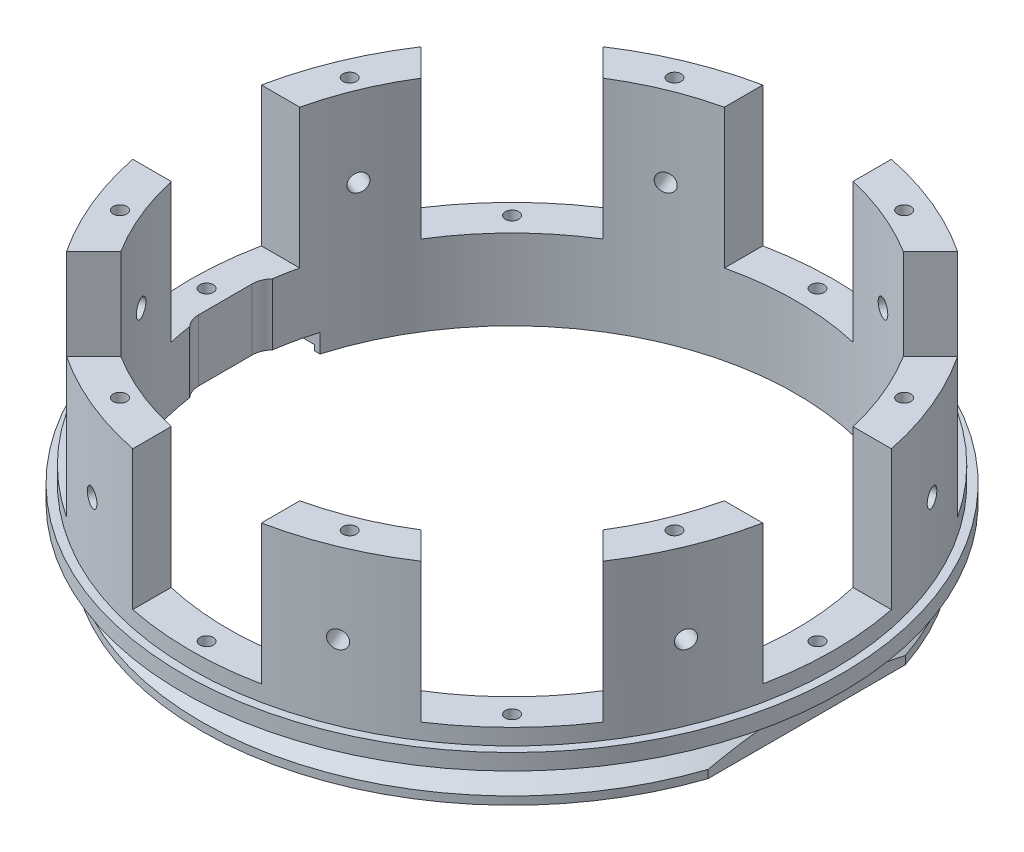
from build123d import *

# Parameters (mm, degrees)
SKIZZE2_W                            = 24
SKIZZE2_H                            = 26
SCHNITT_LINEAR_AUSTRAGEN1_DEPTH      = 62.5
KREISMUSTER1_COUNT                   = 8
SKIZZE3_R                            = 1.65
SCHNITT_LINEAR_AUSTRAGEN2_DEPTH      = 29.067398613
KREISMUSTER2_COUNT                   = 8
SKIZZE4_R                            = 1.25
SCHNITT_LINEAR_AUSTRAGEN3_DEPTH      = 6
SCHNITT_LINEAR_AUSTRAGEN3_DEPTH_BACK = 27.0000001
SCHNITT_LINEAR_AUSTRAGEN4_REACH      = 42
SKIZZE5_W                            = 3
SKIZZE5_H                            = 36.82390528
SKIZZE6_W                            = 7.166939891
SKIZZE6_H                            = 30
SCHNITT_LINEAR_AUSTRAGEN5_DEPTH      = 2.0000001
SCHNITT_LINEAR_AUSTRAGEN5_DEPTH_BACK = 2.5
SKIZZE12_R                           = 1.25
SCHNITT_LINEAR_AUSTRAGEN6_DEPTH      = 10
SCHNITT_LINEAR_AUSTRAGEN7_REACH      = 39.5


with BuildPart() as part:
    # Skizze1 → Rotation1 (revolve)
    with BuildSketch(Plane.XY):
        Polygon((-53, -1), (-53, 40), (-60, 40), (-60, 11), (-61.5, 11), (-61.5, 8), (-55, 8), (-55, 3.600622615), (-58, 1.5), (-58, 0), (-54, 0), (-54, -1), align=None)
    revolve(axis=Axis((0, 0, 0), (0, 1, 0)))

    # Skizze2 → Schnitt-Linear austragen1 (cut, through all)
    with BuildSketch(Plane(origin=(0, 0, 0), x_dir=(0, 0, -1), z_dir=(1, 0, 0))):
        with Locations((0, 27)):
            Rectangle(SKIZZE2_W, SKIZZE2_H)
    schnitt_linear_austragen1 = extrude(amount=-SCHNITT_LINEAR_AUSTRAGEN1_DEPTH, mode=Mode.SUBTRACT)

    # Kreismuster1: Schnitt-Linear austragen1 ×8 about axis
    kreismuster1_axis = Axis((0, 0, 0), (0, 1, 0))
    for i in range(1, KREISMUSTER1_COUNT):
        add(schnitt_linear_austragen1.rotate(kreismuster1_axis, i * 360 / KREISMUSTER1_COUNT), mode=Mode.SUBTRACT)

    # Skizze3 → Schnitt-Linear austragen2 (cut, through all)
    with BuildSketch(Plane(origin=(20.009071561, 0, 48.306171934), x_dir=(-0.923879533, 0, 0.382683432), z_dir=(-0.382683432, 0, -0.923879533))):
        with Locations((0, 25)):
            Circle(SKIZZE3_R)
    schnitt_linear_austragen2 = extrude(amount=-SCHNITT_LINEAR_AUSTRAGEN2_DEPTH, mode=Mode.SUBTRACT)

    # Kreismuster2: Schnitt-Linear austragen2 ×8 about axis
    kreismuster2_axis = Axis((0, 0, 0), (0, -1, 0))
    for i in range(1, KREISMUSTER2_COUNT):
        add(schnitt_linear_austragen2.rotate(kreismuster2_axis, i * 360 / KREISMUSTER2_COUNT), mode=Mode.SUBTRACT)

    # Skizze4 → Schnitt-Linear austragen3 (cut, two sides)
    with BuildSketch(Plane(origin=(0, 14, 0), x_dir=(-1, 0, 0), z_dir=(0, -1, 0))) as schnitt_linear_austragen3_sk:
        with Locations((0, 57)):
            Circle(SKIZZE4_R)
        with Locations((40.305086528, 40.305086528)):
            Circle(SKIZZE4_R)
        with Locations((57, 0)):
            Circle(SKIZZE4_R)
        with Locations((40.305086528, -40.305086528)):
            Circle(SKIZZE4_R)
        with Locations((0, -57)):
            Circle(SKIZZE4_R)
        with Locations((-40.305086528, -40.305086528)):
            Circle(SKIZZE4_R)
        with Locations((-57, 0)):
            Circle(SKIZZE4_R)
        with Locations((-40.305086528, 40.305086528)):
            Circle(SKIZZE4_R)
    extrude(amount=SCHNITT_LINEAR_AUSTRAGEN3_DEPTH, mode=Mode.SUBTRACT)
    extrude(schnitt_linear_austragen3_sk.sketch, amount=-SCHNITT_LINEAR_AUSTRAGEN3_DEPTH_BACK, mode=Mode.SUBTRACT)

    # Skizze5 → Schnitt-Linear austragen4 (cut, up to next)
    with BuildSketch(Plane.XZ, mode=Mode.PRIVATE) as schnitt_linear_austragen4_sk1:
        with Locations((56.5, 0)):
            Rectangle(SKIZZE5_W, SKIZZE5_H)
    schnitt_linear_austragen4_tool1 = extrude(schnitt_linear_austragen4_sk1.sketch, amount=-SCHNITT_LINEAR_AUSTRAGEN4_REACH, mode=Mode.PRIVATE) & part.part
    add(schnitt_linear_austragen4_tool1.solids().sort_by_distance((56.5, 0, 0))[0], mode=Mode.SUBTRACT)

    # Skizze6 → Schnitt-Linear austragen5 (cut, two sides)
    with BuildSketch(Plane.XZ) as schnitt_linear_austragen5_sk:
        with Locations((-54.416530055, 0)):
            Rectangle(SKIZZE6_W, SKIZZE6_H)
    extrude(amount=SCHNITT_LINEAR_AUSTRAGEN5_DEPTH, mode=Mode.SUBTRACT)
    extrude(schnitt_linear_austragen5_sk.sketch, amount=-SCHNITT_LINEAR_AUSTRAGEN5_DEPTH_BACK, mode=Mode.SUBTRACT)

    # Skizze12 → Schnitt-Linear austragen6 (cut)
    with BuildSketch(Plane(origin=(0, 40, 0), x_dir=(1, 0, 0), z_dir=(0, 1, 0))):
        with Locations((-51.737253821, -21.430272212)):
            Circle(SKIZZE12_R)
        with Locations((-51.737253821, 21.430272212)):
            Circle(SKIZZE12_R)
        with Locations((-21.430272212, 51.737253821)):
            Circle(SKIZZE12_R)
        with Locations((21.430272212, 51.737253821)):
            Circle(SKIZZE12_R)
        with Locations((51.737253821, 21.430272212)):
            Circle(SKIZZE12_R)
        with Locations((51.737253821, -21.430272212)):
            Circle(SKIZZE12_R)
        with Locations((21.430272212, -51.737253821)):
            Circle(SKIZZE12_R)
        with Locations((-21.430272212, -51.737253821)):
            Circle(SKIZZE12_R)
    extrude(amount=-SCHNITT_LINEAR_AUSTRAGEN6_DEPTH, mode=Mode.SUBTRACT)

    # Skizze13 → Schnitt-Linear austragen7 (cut, up to next)
    with BuildSketch(Plane.XZ.offset(-2.5), mode=Mode.PRIVATE) as schnitt_linear_austragen7_sk1:
        with BuildLine():
            Line((-53.5, -5), (-53.5, 5))
            ThreePointArc((-53.5, 5), (-49.5, 9), (-45.5, 5))
            Line((-45.5, 5), (-45.5, -5))
            ThreePointArc((-45.5, -5), (-49.5, -9), (-53.5, -5))
        make_face()
    schnitt_linear_austragen7_tool1 = extrude(schnitt_linear_austragen7_sk1.sketch, amount=-SCHNITT_LINEAR_AUSTRAGEN7_REACH, mode=Mode.PRIVATE) & part.part
    add(schnitt_linear_austragen7_tool1.solids().sort_by_distance((-49.5, 2.5, 0))[0], mode=Mode.SUBTRACT)


solid = part.part
